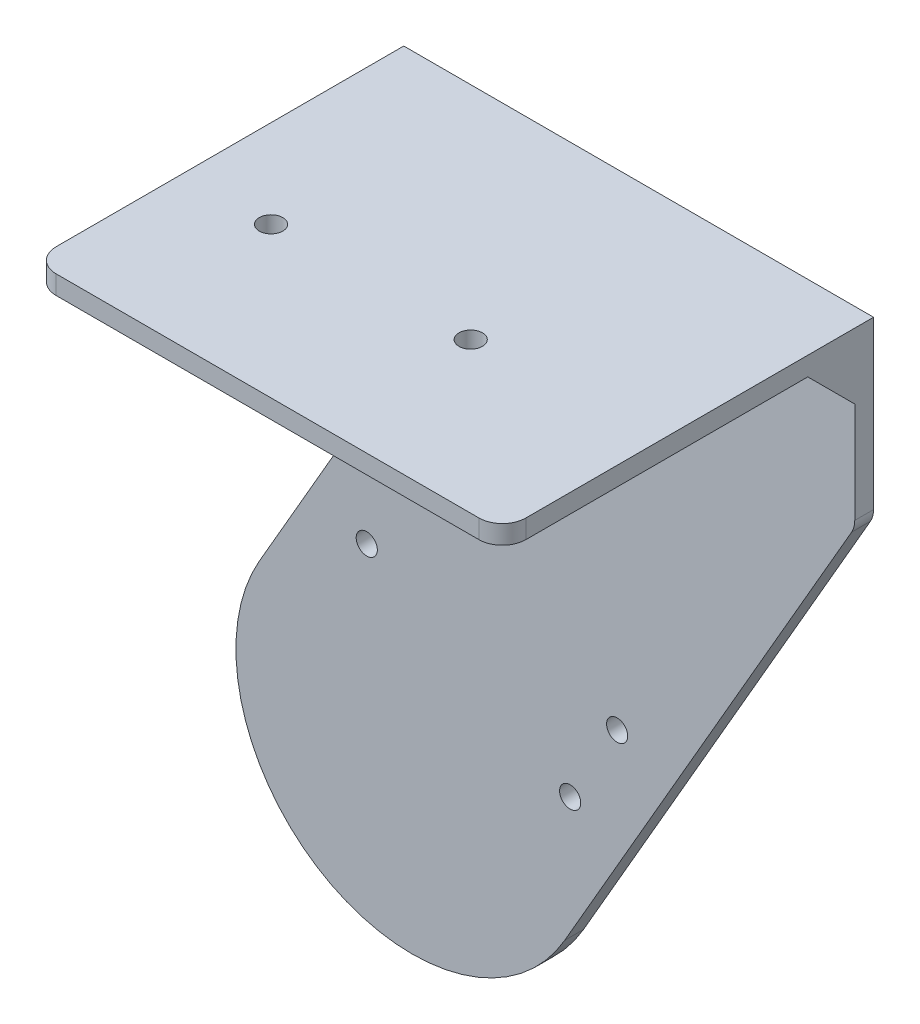
from build123d import *

# Parameters (mm, degrees)
BOSS_EXTRUDE1_DEPTH = 8
SKETCH4_W           = 150
SKETCH4_H           = 8
BOSS_EXTRUDE2_DEPTH = 200
CHAMFER1_SIZE       = 20
CUT_EXTRUDE1_REACH  = 327
SKETCH5_R           = 5
CUT_EXTRUDE2_REACH  = 10
SKETCH6_R           = 4.5
FILLET1_R           = 10


with BuildPart() as part:
    # Sketch1 → Boss-Extrude1 (new body)
    with BuildSketch(Plane.XY):
        with BuildLine():
            Line((-64.951905284, 37.5), (-11.547005384, 130))
            Line((-11.547005384, 130), (-11.547005384, 250))
            Line((-11.547005384, 250), (188.452994616, 250))
            Line((188.452994616, 250), (188.452994616, 176.410161514))
            Line((188.452994616, 176.410161514), (64.951905284, -37.5))
            ThreePointArc((64.951905284, -37.5), (-37.5, -64.951905284), (-64.951905284, 37.5))
        make_face()
    extrude(amount=BOSS_EXTRUDE1_DEPTH)

    # Sketch4 → Boss-Extrude2 (add)
    with BuildSketch(Plane.ZY.offset(11.547005384)):
        with Locations((83, 246)):
            Rectangle(SKETCH4_W, SKETCH4_H)
    extrude(amount=-BOSS_EXTRUDE2_DEPTH)

    # Chamfer1
    chamfer1_edges = [part.edges().sort_by_distance(p)[0] for p in [
        (88.452994616, 242, 8),
    ]]
    chamfer(chamfer1_edges, length=CHAMFER1_SIZE)

    # Sketch5 → Cut-Extrude1 (cut, up to next)
    with BuildSketch(Plane(origin=(0, 250, 0), x_dir=(1, 0, 0), z_dir=(0, 1, 0)), mode=Mode.PRIVATE) as cut_extrude1_sk1:
        with Locations((25.952994616, -94)):
            Circle(SKETCH5_R)
    cut_extrude1_tool1 = extrude(cut_extrude1_sk1.sketch, amount=-CUT_EXTRUDE1_REACH, mode=Mode.PRIVATE) & part.part
    add(cut_extrude1_tool1.solids().sort_by_distance((25.952995, 250, 94))[0], mode=Mode.SUBTRACT)
    # Sketch5 → Cut-Extrude1 (cut, up to next)
    with BuildSketch(Plane(origin=(0, 250, 0), x_dir=(1, 0, 0), z_dir=(0, 1, 0)), mode=Mode.PRIVATE) as cut_extrude1_sk2:
        with Locations((110.952994616, -94)):
            Circle(SKETCH5_R)
    cut_extrude1_tool2 = extrude(cut_extrude1_sk2.sketch, amount=-CUT_EXTRUDE1_REACH, mode=Mode.PRIVATE) & part.part
    add(cut_extrude1_tool2.solids().sort_by_distance((110.952995, 250, 94))[0], mode=Mode.SUBTRACT)

    # Sketch6 → Cut-Extrude2 (cut, up to next)
    with BuildSketch(Plane.XY.offset(8), mode=Mode.PRIVATE) as cut_extrude2_sk1:
        with Locations((0.698729811, 101.210235533)):
            Circle(SKETCH6_R)
    cut_extrude2_tool1 = extrude(cut_extrude2_sk1.sketch, amount=-CUT_EXTRUDE2_REACH, mode=Mode.PRIVATE) & part.part
    add(cut_extrude2_tool1.solids().sort_by_distance((0.69873, 101.210236, 8))[0], mode=Mode.SUBTRACT)
    # Sketch6 → Cut-Extrude2 (cut, up to next)
    with BuildSketch(Plane.XY.offset(8), mode=Mode.PRIVATE) as cut_extrude2_sk2:
        with Locations((87.301270189, 51.210235533)):
            Circle(SKETCH6_R)
    cut_extrude2_tool2 = extrude(cut_extrude2_sk2.sketch, amount=-CUT_EXTRUDE2_REACH, mode=Mode.PRIVATE) & part.part
    add(cut_extrude2_tool2.solids().sort_by_distance((87.30127, 51.210236, 8))[0], mode=Mode.SUBTRACT)
    # Sketch6 → Cut-Extrude2 (cut, up to next)
    with BuildSketch(Plane.XY.offset(8), mode=Mode.PRIVATE) as cut_extrude2_sk3:
        with Locations((67.301270189, 16.569219382)):
            Circle(SKETCH6_R)
    cut_extrude2_tool3 = extrude(cut_extrude2_sk3.sketch, amount=-CUT_EXTRUDE2_REACH, mode=Mode.PRIVATE) & part.part
    add(cut_extrude2_tool3.solids().sort_by_distance((67.30127, 16.569219, 8))[0], mode=Mode.SUBTRACT)
    # Sketch6 → Cut-Extrude2 (cut, up to next)
    with BuildSketch(Plane.XY.offset(8), mode=Mode.PRIVATE) as cut_extrude2_sk4:
        with Locations((-19.301270189, 66.569219382)):
            Circle(SKETCH6_R)
    cut_extrude2_tool4 = extrude(cut_extrude2_sk4.sketch, amount=-CUT_EXTRUDE2_REACH, mode=Mode.PRIVATE) & part.part
    add(cut_extrude2_tool4.solids().sort_by_distance((-19.30127, 66.569219, 8))[0], mode=Mode.SUBTRACT)

    # Fillet1
    fillet1_edges = [part.edges().sort_by_distance(p)[0] for p in [
        (-11.547005384, 130, 4),
        (188.452994616, 176.410161514, 4),
        (188.452994616, 246, 158),
        (-11.547005384, 246, 158),
    ]]
    fillet(fillet1_edges, radius=FILLET1_R)


solid = part.part
